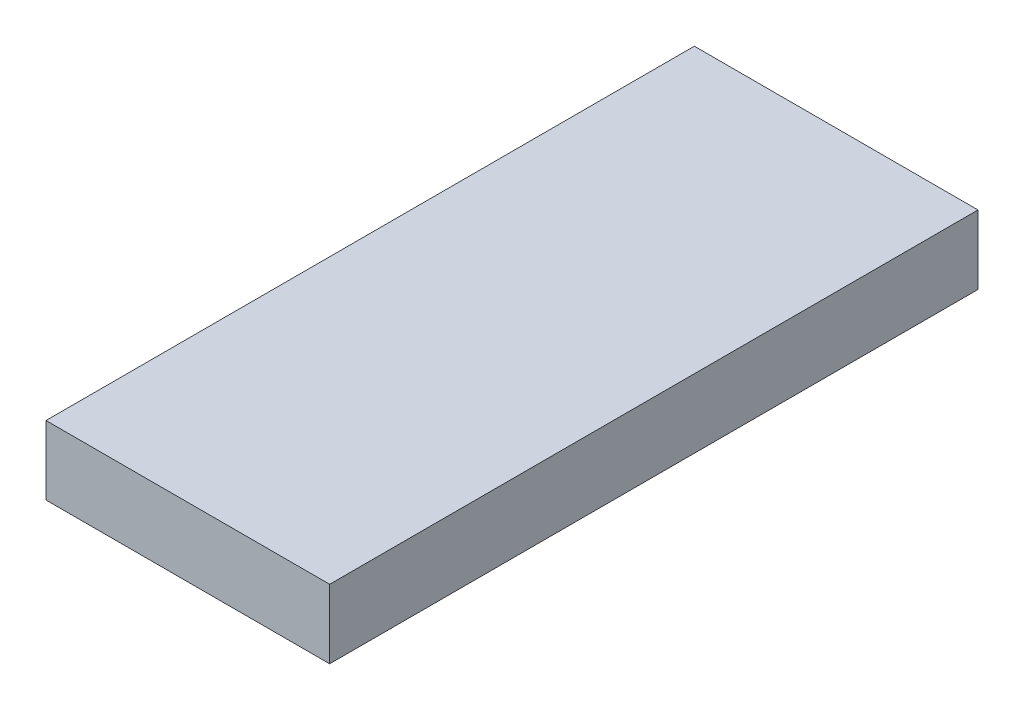
from build123d import *

# Parameters (mm, degrees)
ESQUISSE1_W      = 7
ESQUISSE1_H      = 1.7
EXTRUSION1_DEPTH = 16


with BuildPart() as part:
    # Esquisse1 → Extrusion1 (new body)
    with BuildSketch(Plane.XY):
        with Locations((0, 0.85)):
            Rectangle(ESQUISSE1_W, ESQUISSE1_H)
    extrude(amount=EXTRUSION1_DEPTH)


solid = part.part
